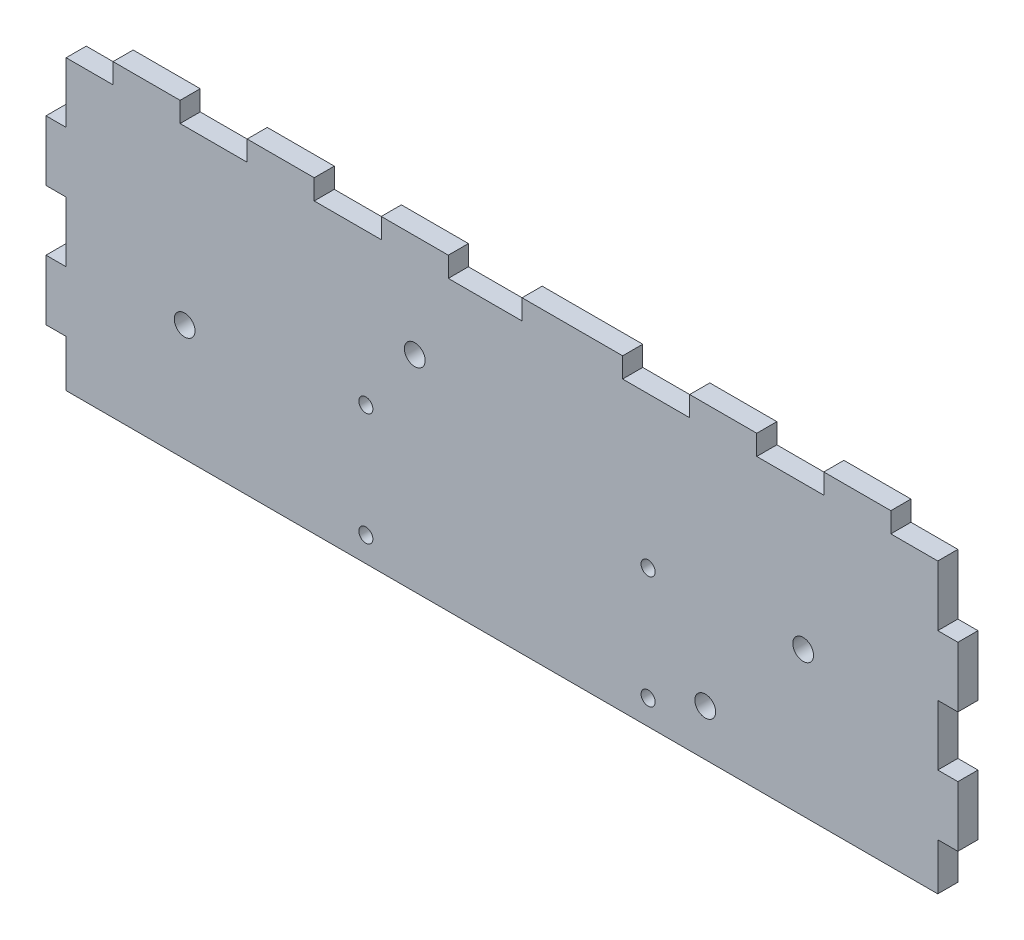
from build123d import *

# Parameters (mm, degrees)
SKETCH1_W           = 136
SKETCH1_H           = 46
BOSS_EXTRUDE1_DEPTH = 3
CUT_EXTRUDE1_REACH  = 5
SKETCH4_W           = 3
SKETCH4_H           = 9
SKETCH4_H_2         = 7
SKETCH4_W_2         = 10
SKETCH4_H_3         = 3
SKETCH4_W_3         = 11
CUT_EXTRUDE2_REACH  = 5
SKETCH5_R           = 1.05
SKETCH5_R_2         = 1.55


with BuildPart() as part:
    # Sketch1 → Boss-Extrude1 (new body)
    with BuildSketch(Plane.XY):
        with Locations((68, 23)):
            Rectangle(SKETCH1_W, SKETCH1_H)
    extrude(amount=BOSS_EXTRUDE1_DEPTH)

    # Sketch4 → Cut-Extrude1 (cut, up to next)
    with BuildSketch(Plane.XY.offset(3), mode=Mode.PRIVATE) as cut_extrude1_sk1:
        Polygon((0, 46), (0, 43), (3, 43), (10, 43), (10, 46), align=None)
    cut_extrude1_tool1 = extrude(cut_extrude1_sk1.sketch, amount=-CUT_EXTRUDE1_REACH, mode=Mode.PRIVATE) & part.part
    add(cut_extrude1_tool1.solids().sort_by_distance((5, 44.5, 3))[0], mode=Mode.SUBTRACT)
    # Sketch4 → Cut-Extrude1 (cut, up to next)
    with BuildSketch(Plane.XY.offset(3), mode=Mode.PRIVATE) as cut_extrude1_sk2:
        with Locations((1.5, 38.5)):
            Rectangle(SKETCH4_W, SKETCH4_H)
    cut_extrude1_tool2 = extrude(cut_extrude1_sk2.sketch, amount=-CUT_EXTRUDE1_REACH, mode=Mode.PRIVATE) & part.part
    add(cut_extrude1_tool2.solids().sort_by_distance((1.5, 38.5, 3))[0], mode=Mode.SUBTRACT)
    # Sketch4 → Cut-Extrude1 (cut, up to next)
    with BuildSketch(Plane.XY.offset(3), mode=Mode.PRIVATE) as cut_extrude1_sk3:
        with Locations((1.5, 20.5)):
            Rectangle(SKETCH4_W, SKETCH4_H)
    cut_extrude1_tool3 = extrude(cut_extrude1_sk3.sketch, amount=-CUT_EXTRUDE1_REACH, mode=Mode.PRIVATE) & part.part
    add(cut_extrude1_tool3.solids().sort_by_distance((1.5, 20.5, 3))[0], mode=Mode.SUBTRACT)
    # Sketch4 → Cut-Extrude1 (cut, up to next)
    with BuildSketch(Plane.XY.offset(3), mode=Mode.PRIVATE) as cut_extrude1_sk4:
        with Locations((1.5, 3.5)):
            Rectangle(SKETCH4_W, SKETCH4_H_2)
    cut_extrude1_tool4 = extrude(cut_extrude1_sk4.sketch, amount=-CUT_EXTRUDE1_REACH, mode=Mode.PRIVATE) & part.part
    add(cut_extrude1_tool4.solids().sort_by_distance((1.5, 3.5, 3))[0], mode=Mode.SUBTRACT)
    # Sketch4 → Cut-Extrude1 (cut, up to next)
    with BuildSketch(Plane.XY.offset(3), mode=Mode.PRIVATE) as cut_extrude1_sk5:
        with Locations((25, 44.5)):
            Rectangle(SKETCH4_W_2, SKETCH4_H_3)
    cut_extrude1_tool5 = extrude(cut_extrude1_sk5.sketch, amount=-CUT_EXTRUDE1_REACH, mode=Mode.PRIVATE) & part.part
    add(cut_extrude1_tool5.solids().sort_by_distance((25, 44.5, 3))[0], mode=Mode.SUBTRACT)
    # Sketch4 → Cut-Extrude1 (cut, up to next)
    with BuildSketch(Plane.XY.offset(3), mode=Mode.PRIVATE) as cut_extrude1_sk6:
        with Locations((45, 44.5)):
            Rectangle(SKETCH4_W_2, SKETCH4_H_3)
    cut_extrude1_tool6 = extrude(cut_extrude1_sk6.sketch, amount=-CUT_EXTRUDE1_REACH, mode=Mode.PRIVATE) & part.part
    add(cut_extrude1_tool6.solids().sort_by_distance((45, 44.5, 3))[0], mode=Mode.SUBTRACT)
    # Sketch4 → Cut-Extrude1 (cut, up to next)
    with BuildSketch(Plane.XY.offset(3), mode=Mode.PRIVATE) as cut_extrude1_sk7:
        with Locations((65.5, 44.5)):
            Rectangle(SKETCH4_W_3, SKETCH4_H_3)
    cut_extrude1_tool7 = extrude(cut_extrude1_sk7.sketch, amount=-CUT_EXTRUDE1_REACH, mode=Mode.PRIVATE) & part.part
    add(cut_extrude1_tool7.solids().sort_by_distance((65.5, 44.5, 3))[0], mode=Mode.SUBTRACT)
    # Sketch4 → Cut-Extrude1 (cut, up to next)
    with BuildSketch(Plane.XY.offset(3), mode=Mode.PRIVATE) as cut_extrude1_sk8:
        with Locations((91, 44.5)):
            Rectangle(SKETCH4_W_2, SKETCH4_H_3)
    cut_extrude1_tool8 = extrude(cut_extrude1_sk8.sketch, amount=-CUT_EXTRUDE1_REACH, mode=Mode.PRIVATE) & part.part
    add(cut_extrude1_tool8.solids().sort_by_distance((91, 44.5, 3))[0], mode=Mode.SUBTRACT)
    # Sketch4 → Cut-Extrude1 (cut, up to next)
    with BuildSketch(Plane.XY.offset(3), mode=Mode.PRIVATE) as cut_extrude1_sk9:
        with Locations((111, 44.5)):
            Rectangle(SKETCH4_W_2, SKETCH4_H_3)
    cut_extrude1_tool9 = extrude(cut_extrude1_sk9.sketch, amount=-CUT_EXTRUDE1_REACH, mode=Mode.PRIVATE) & part.part
    add(cut_extrude1_tool9.solids().sort_by_distance((111, 44.5, 3))[0], mode=Mode.SUBTRACT)
    # Sketch4 → Cut-Extrude1 (cut, up to next)
    with BuildSketch(Plane.XY.offset(3), mode=Mode.PRIVATE) as cut_extrude1_sk10:
        Polygon((133, 43), (136, 43), (136, 46), (126, 46), (126, 43), align=None)
    cut_extrude1_tool10 = extrude(cut_extrude1_sk10.sketch, amount=-CUT_EXTRUDE1_REACH, mode=Mode.PRIVATE) & part.part
    add(cut_extrude1_tool10.solids().sort_by_distance((131, 44.5, 3))[0], mode=Mode.SUBTRACT)
    # Sketch4 → Cut-Extrude1 (cut, up to next)
    with BuildSketch(Plane.XY.offset(3), mode=Mode.PRIVATE) as cut_extrude1_sk11:
        with Locations((134.5, 38.5)):
            Rectangle(SKETCH4_W, SKETCH4_H)
    cut_extrude1_tool11 = extrude(cut_extrude1_sk11.sketch, amount=-CUT_EXTRUDE1_REACH, mode=Mode.PRIVATE) & part.part
    add(cut_extrude1_tool11.solids().sort_by_distance((134.5, 38.5, 3))[0], mode=Mode.SUBTRACT)
    # Sketch4 → Cut-Extrude1 (cut, up to next)
    with BuildSketch(Plane.XY.offset(3), mode=Mode.PRIVATE) as cut_extrude1_sk12:
        with Locations((134.5, 20.5)):
            Rectangle(SKETCH4_W, SKETCH4_H)
    cut_extrude1_tool12 = extrude(cut_extrude1_sk12.sketch, amount=-CUT_EXTRUDE1_REACH, mode=Mode.PRIVATE) & part.part
    add(cut_extrude1_tool12.solids().sort_by_distance((134.5, 20.5, 3))[0], mode=Mode.SUBTRACT)
    # Sketch4 → Cut-Extrude1 (cut, up to next)
    with BuildSketch(Plane.XY.offset(3), mode=Mode.PRIVATE) as cut_extrude1_sk13:
        with Locations((134.5, 3.5)):
            Rectangle(SKETCH4_W, SKETCH4_H_2)
    cut_extrude1_tool13 = extrude(cut_extrude1_sk13.sketch, amount=-CUT_EXTRUDE1_REACH, mode=Mode.PRIVATE) & part.part
    add(cut_extrude1_tool13.solids().sort_by_distance((134.5, 3.5, 3))[0], mode=Mode.SUBTRACT)

    # Sketch5 → Cut-Extrude2 (cut, up to next)
    with BuildSketch(Plane(origin=(0, 0, 0), x_dir=(-1, 0, 0), z_dir=(0, 0, -1)), mode=Mode.PRIVATE) as cut_extrude2_sk1:
        with Locations((-89.8, 20.5)):
            Circle(SKETCH5_R)
    cut_extrude2_tool1 = extrude(cut_extrude2_sk1.sketch, amount=-CUT_EXTRUDE2_REACH, mode=Mode.PRIVATE) & part.part
    add(cut_extrude2_tool1.solids().sort_by_distance((89.8, 20.5, 0))[0], mode=Mode.SUBTRACT)
    # Sketch5 → Cut-Extrude2 (cut, up to next)
    with BuildSketch(Plane(origin=(0, 0, 0), x_dir=(-1, 0, 0), z_dir=(0, 0, -1)), mode=Mode.PRIVATE) as cut_extrude2_sk2:
        with Locations((-89.8, 3.7)):
            Circle(SKETCH5_R)
    cut_extrude2_tool2 = extrude(cut_extrude2_sk2.sketch, amount=-CUT_EXTRUDE2_REACH, mode=Mode.PRIVATE) & part.part
    add(cut_extrude2_tool2.solids().sort_by_distance((89.8, 3.7, 0))[0], mode=Mode.SUBTRACT)
    # Sketch5 → Cut-Extrude2 (cut, up to next)
    with BuildSketch(Plane(origin=(0, 0, 0), x_dir=(-1, 0, 0), z_dir=(0, 0, -1)), mode=Mode.PRIVATE) as cut_extrude2_sk3:
        with Locations((-47.7, 20.5)):
            Circle(SKETCH5_R)
    cut_extrude2_tool3 = extrude(cut_extrude2_sk3.sketch, amount=-CUT_EXTRUDE2_REACH, mode=Mode.PRIVATE) & part.part
    add(cut_extrude2_tool3.solids().sort_by_distance((47.7, 20.5, 0))[0], mode=Mode.SUBTRACT)
    # Sketch5 → Cut-Extrude2 (cut, up to next)
    with BuildSketch(Plane(origin=(0, 0, 0), x_dir=(-1, 0, 0), z_dir=(0, 0, -1)), mode=Mode.PRIVATE) as cut_extrude2_sk4:
        with Locations((-47.7, 3.7)):
            Circle(SKETCH5_R)
    cut_extrude2_tool4 = extrude(cut_extrude2_sk4.sketch, amount=-CUT_EXTRUDE2_REACH, mode=Mode.PRIVATE) & part.part
    add(cut_extrude2_tool4.solids().sort_by_distance((47.7, 3.7, 0))[0], mode=Mode.SUBTRACT)
    # Sketch5 → Cut-Extrude2 (cut, up to next)
    with BuildSketch(Plane(origin=(0, 0, 0), x_dir=(-1, 0, 0), z_dir=(0, 0, -1)), mode=Mode.PRIVATE) as cut_extrude2_sk5:
        with Locations((-20.677552724, 17.314204089)):
            Circle(SKETCH5_R_2)
    cut_extrude2_tool5 = extrude(cut_extrude2_sk5.sketch, amount=-CUT_EXTRUDE2_REACH, mode=Mode.PRIVATE) & part.part
    add(cut_extrude2_tool5.solids().sort_by_distance((20.677553, 17.314204, 0))[0], mode=Mode.SUBTRACT)
    # Sketch5 → Cut-Extrude2 (cut, up to next)
    with BuildSketch(Plane(origin=(0, 0, 0), x_dir=(-1, 0, 0), z_dir=(0, 0, -1)), mode=Mode.PRIVATE) as cut_extrude2_sk6:
        with Locations((-55, 30.651276125)):
            Circle(SKETCH5_R_2)
    cut_extrude2_tool6 = extrude(cut_extrude2_sk6.sketch, amount=-CUT_EXTRUDE2_REACH, mode=Mode.PRIVATE) & part.part
    add(cut_extrude2_tool6.solids().sort_by_distance((55, 30.651276, 0))[0], mode=Mode.SUBTRACT)
    # Sketch5 → Cut-Extrude2 (cut, up to next)
    with BuildSketch(Plane(origin=(0, 0, 0), x_dir=(-1, 0, 0), z_dir=(0, 0, -1)), mode=Mode.PRIVATE) as cut_extrude2_sk7:
        with Locations((-112.926148706, 21.541179951)):
            Circle(SKETCH5_R_2)
    cut_extrude2_tool7 = extrude(cut_extrude2_sk7.sketch, amount=-CUT_EXTRUDE2_REACH, mode=Mode.PRIVATE) & part.part
    add(cut_extrude2_tool7.solids().sort_by_distance((112.926149, 21.54118, 0))[0], mode=Mode.SUBTRACT)
    # Sketch5 → Cut-Extrude2 (cut, up to next)
    with BuildSketch(Plane(origin=(0, 0, 0), x_dir=(-1, 0, 0), z_dir=(0, 0, -1)), mode=Mode.PRIVATE) as cut_extrude2_sk8:
        with Locations((-98.323238206, 6.929404951)):
            Circle(SKETCH5_R_2)
    cut_extrude2_tool8 = extrude(cut_extrude2_sk8.sketch, amount=-CUT_EXTRUDE2_REACH, mode=Mode.PRIVATE) & part.part
    add(cut_extrude2_tool8.solids().sort_by_distance((98.323238, 6.929405, 0))[0], mode=Mode.SUBTRACT)


solid = part.part
